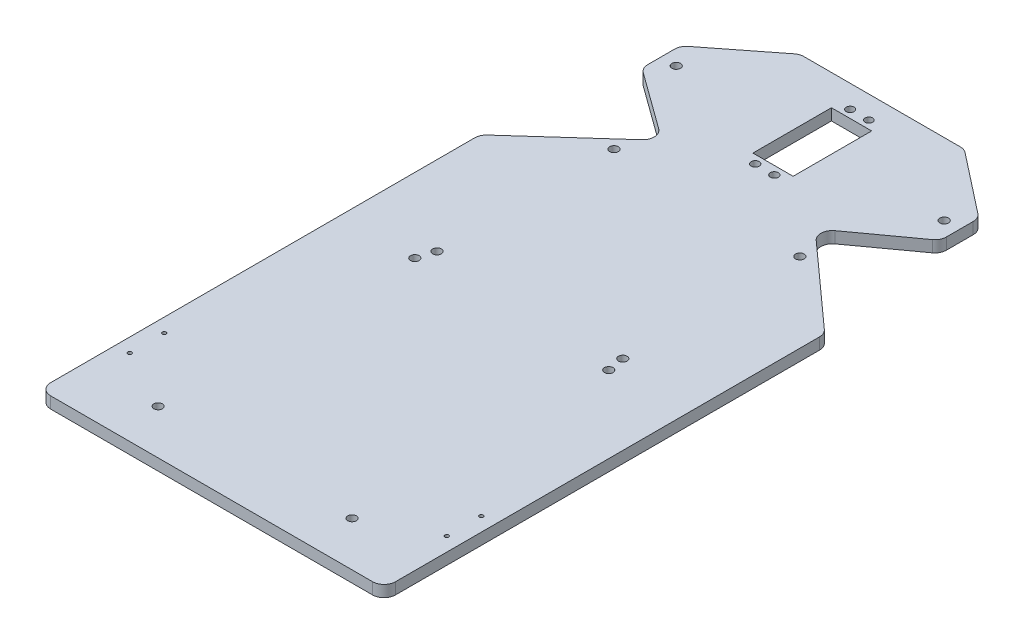
from build123d import *

# Parameters (mm, degrees)
SALIENTE_EXTRUIR1_DEPTH = 6
CROQUIS2_W              = 21
CROQUIS2_H              = 41
CORTAR_EXTRUIR1_DEPTH   = 10
CROQUIS3_R              = 1
CORTAR_EXTRUIR2_DEPTH   = 10
CROQUIS4_R              = 2.25
CORTAR_EXTRUIR3_DEPTH   = 10
CROQUIS5_R              = 2.25
CORTAR_EXTRUIR4_DEPTH   = 10
CROQUIS9_R              = 2.25
CORTAR_EXTRUIR6_DEPTH   = 29
CROQUIS6_R              = 2.064168912
CROQUIS6_R_2            = 1.970714146
CROQUIS6_R_3            = 2.1
CORTAR_EXTRUIR7_DEPTH   = 10
REDONDEO1_R             = 6


with BuildPart() as part:
    # Croquis1 → Saliente-Extruir1 (new body)
    with BuildSketch(Plane(origin=(0, 0, 0), x_dir=(1, 0, 0), z_dir=(0, 1, 0))):
        Polygon((-55.627306273, -217.492892842), (-55.627306273, 12.564575646), (-5.627306273, 57.564575646), (-43.56277397, 85.075402887), (-43.56277397, 105.075421235), (-8.56277397, 132.507107158), (77.308161424, 132.507107158), (112.308161424, 105.074865922), (112.308161424, 85.073844823), (74.372693727, 57.564575646), (124.372693727, 12.564575646), (124.372693727, -217.492892842), align=None)
    extrude(amount=SALIENTE_EXTRUIR1_DEPTH)

    # Croquis2 → Cortar-Extruir1 (cut)
    with BuildSketch(Plane(origin=(0, 6, 0), x_dir=(1, 0, 0), z_dir=(0, 1, 0))):
        with Locations((34.372693727, 96.064575646)):
            Rectangle(CROQUIS2_W, CROQUIS2_H)
    extrude(amount=-CORTAR_EXTRUIR1_DEPTH, mode=Mode.SUBTRACT)

    # Croquis3 → Cortar-Extruir2 (cut)
    with BuildSketch(Plane(origin=(0, 6, 0), x_dir=(1, 0, 0), z_dir=(0, 1, 0))):
        with Locations((117.122693727, -177.492892842)):
            Circle(CROQUIS3_R)
        with Locations((117.122693727, -159.492892842)):
            Circle(CROQUIS3_R)
        with Locations((-48.377306273, -159.492892842)):
            Circle(CROQUIS3_R)
        with Locations((-48.377306273, -177.492892842)):
            Circle(CROQUIS3_R)
    extrude(amount=-CORTAR_EXTRUIR2_DEPTH, mode=Mode.SUBTRACT)

    # Croquis4 → Cortar-Extruir3 (cut)
    with BuildSketch(Plane(origin=(0, 6, 0), x_dir=(1, 0, 0), z_dir=(0, 1, 0))):
        with Locations((-16.877306273, -194.17563761)):
            Circle(CROQUIS4_R)
        with Locations((-16.877306273, -60.17563761)):
            Circle(CROQUIS4_R)
        with Locations((84.372693727, -60.17563761)):
            Circle(CROQUIS4_R)
        with Locations((84.372693727, -194.17563761)):
            Circle(CROQUIS4_R)
    extrude(amount=-CORTAR_EXTRUIR3_DEPTH, mode=Mode.SUBTRACT)

    # Croquis5 → Cortar-Extruir4 (cut)
    with BuildSketch(Plane(origin=(0, 6, 0), x_dir=(1, 0, 0), z_dir=(0, 1, 0))):
        with Locations((82.872693727, -51.34563761)):
            Circle(CROQUIS5_R)
        with Locations((-14.127306273, -51.34563761)):
            Circle(CROQUIS5_R)
        with Locations((-14.127306273, 41.07436239)):
            Circle(CROQUIS5_R)
        with Locations((82.872693727, 41.07436239)):
            Circle(CROQUIS5_R)
    extrude(amount=-CORTAR_EXTRUIR4_DEPTH, mode=Mode.SUBTRACT)

    # Croquis9 → Cortar-Extruir6 (cut)
    with BuildSketch(Plane(origin=(0, 0, 0), x_dir=(-1, 0, 0), z_dir=(0, -1, 0))):
        with Locations((-104.308161424, 94.983735042)):
            Circle(CROQUIS9_R)
        with Locations((35.56277397, 94.983735042)):
            Circle(CROQUIS9_R)
    extrude(amount=-CORTAR_EXTRUIR6_DEPTH, mode=Mode.SUBTRACT)

    # Croquis6 → Cortar-Extruir7 (cut)
    with BuildSketch(Plane(origin=(0, 0, 0), x_dir=(-1, 0, 0), z_dir=(0, -1, 0))):
        with Locations((-29.512693727, 120.689890176)):
            Circle(CROQUIS6_R)
        with Locations((-39.232693727, 120.725721264)):
            Circle(CROQUIS6_R_2)
        with Locations((-39.362693727, 71.26759894)):
            Circle(CROQUIS6_R_3)
        with Locations((-29.382693727, 71.26759894)):
            Circle(CROQUIS6_R_3)
    extrude(amount=-CORTAR_EXTRUIR7_DEPTH, mode=Mode.SUBTRACT)

    # Redondeo1
    redondeo1_edges = [part.edges().sort_by_distance(p)[0] for p in [
        (-55.627306273, 3, 217.492892842),
        (-55.627306273, 3, -12.564575646),
        (-5.627306273, 3, -57.564575646),
        (-43.56277397, 3, -85.075402887),
        (-43.56277397, 3, -105.075421235),
        (-8.56277397, 3, -132.507107158),
        (77.308161424, 3, -132.507107158),
        (112.308161424, 3, -105.074865922),
        (112.308161424, 3, -85.073844823),
        (74.372693727, 3, -57.564575646),
        (124.372693727, 3, -12.564575646),
        (124.372693727, 3, 217.492892842),
    ]]
    fillet(redondeo1_edges, radius=REDONDEO1_R)


solid = part.part
